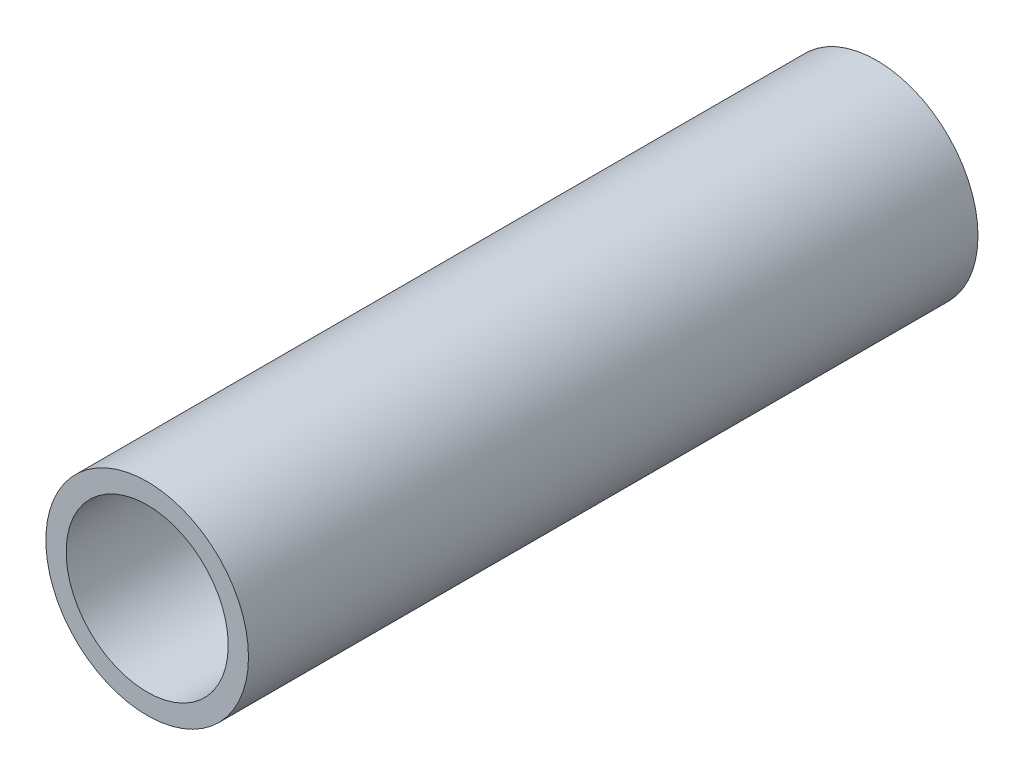
from build123d import *

# Parameters (mm, degrees)
SKETCH1_R           = 1.25
SKETCH1_R_2         = 1
BOSS_EXTRUDE1_DEPTH = 9


with BuildPart() as part:
    # Sketch1 → Boss-Extrude1 (new body)
    with BuildSketch(Plane.XY):
        Circle(SKETCH1_R)
        Circle(SKETCH1_R_2, mode=Mode.SUBTRACT)
    extrude(amount=BOSS_EXTRUDE1_DEPTH)


solid = part.part
